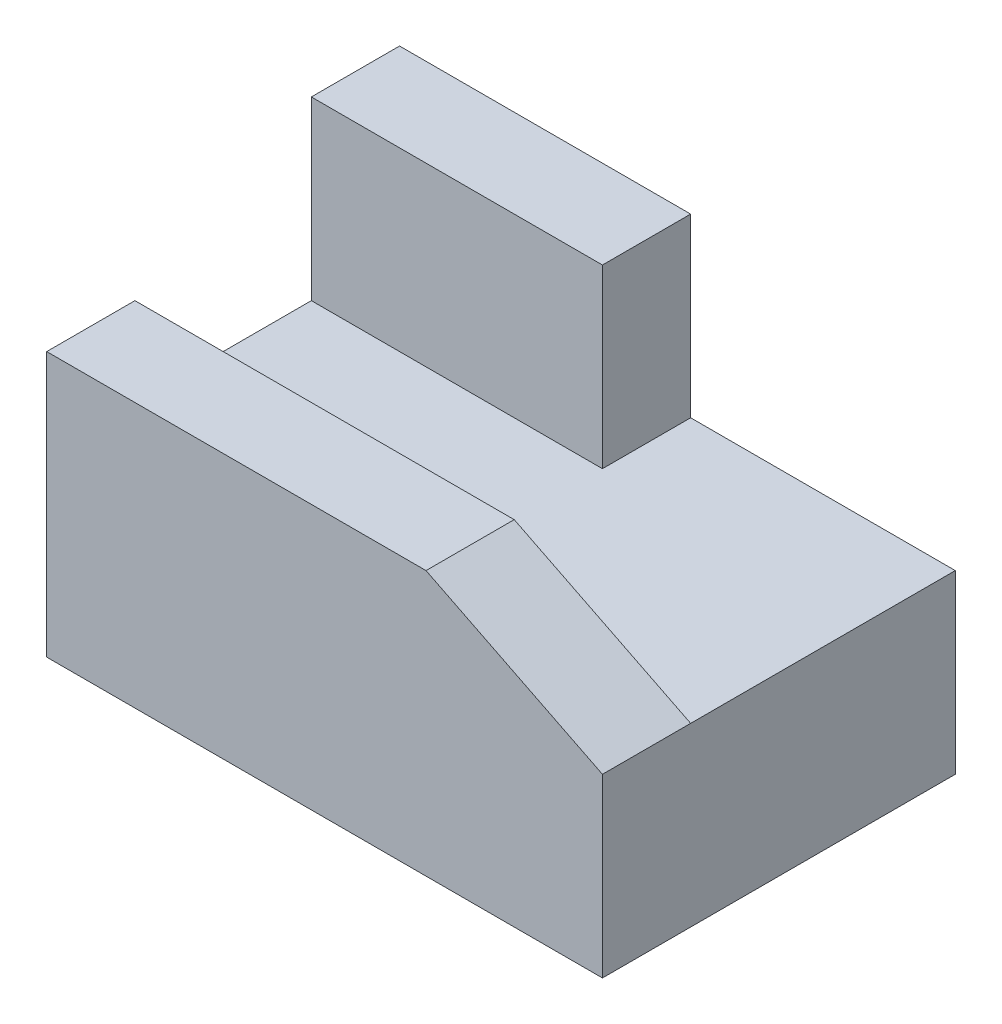
from build123d import *

# Parameters (mm, degrees)
BOSS_EXTRUDE1_DEPTH     = 20
SKETCH1_3_W             = 63
SKETCH1_3_H             = 10
BOSS_EXTRUDE2_DEPTH     = 30
SKETCH1_4_W             = 33
SKETCH1_4_H             = 10
BOSS_EXTRUDE3_DEPTH     = 40
CUT_EXTRUDE1_DEPTH      = 31
CUT_EXTRUDE1_DEPTH_BACK = 10


with BuildPart() as part:
    # Sketch1 → Boss-Extrude1 (new body)
    with BuildSketch(Plane(origin=(0, 0, 0), x_dir=(1, 0, 0), z_dir=(0, 1, 0))):
        Polygon((33, 30), (0, 30), (0, 10), (63, 10), (63, 40), (33, 40), align=None)
    extrude(amount=BOSS_EXTRUDE1_DEPTH)

    # Sketch1_3 → Boss-Extrude2 (add)
    with BuildSketch(Plane(origin=(0, 0, 0), x_dir=(1, 0, 0), z_dir=(0, 1, 0))):
        with Locations((31.5, 5)):
            Rectangle(SKETCH1_3_W, SKETCH1_3_H)
    extrude(amount=BOSS_EXTRUDE2_DEPTH)

    # Sketch1_4 → Boss-Extrude3 (add)
    with BuildSketch(Plane(origin=(0, 0, 0), x_dir=(1, 0, 0), z_dir=(0, 1, 0))):
        with Locations((16.5, 35)):
            Rectangle(SKETCH1_4_W, SKETCH1_4_H)
    extrude(amount=BOSS_EXTRUDE3_DEPTH)

    # Sketch2 → Cut-Extrude1 (cut, two sides)
    with BuildSketch(Plane(origin=(0, 0, -10), x_dir=(-1, 0, 0), z_dir=(0, 0, -1))) as cut_extrude1_sk:
        Polygon((-63, 30), (-63, 20), (-43, 30), align=None)
    extrude(amount=CUT_EXTRUDE1_DEPTH, mode=Mode.SUBTRACT)
    extrude(cut_extrude1_sk.sketch, amount=-CUT_EXTRUDE1_DEPTH_BACK, mode=Mode.SUBTRACT)


solid = part.part
